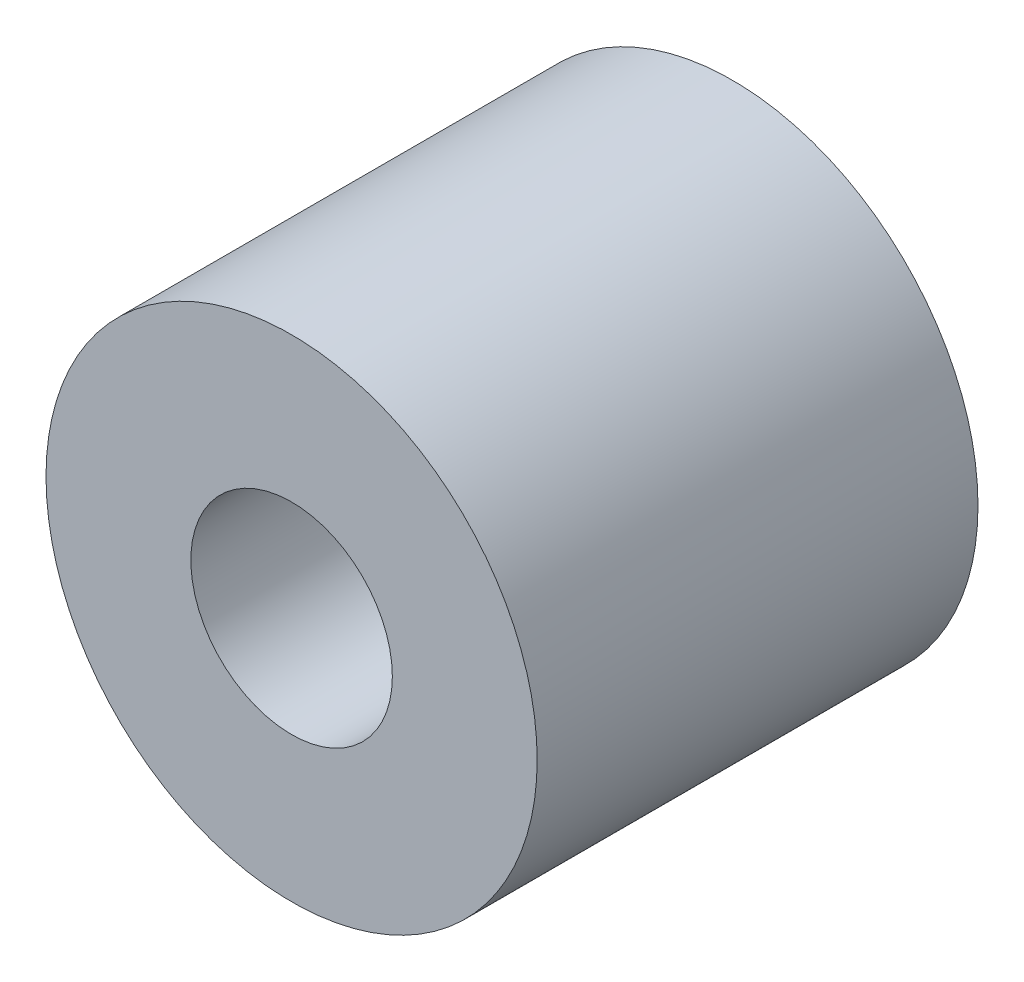
from build123d import *

# Parameters (mm, degrees)
SKETCH1_R           = 3.9
SKETCH1_R_2         = 1.6
BOSS_EXTRUDE1_DEPTH = 7


with BuildPart() as part:
    # Sketch1 → Boss-Extrude1 (new body)
    with BuildSketch(Plane.XY):
        Circle(SKETCH1_R)
        Circle(SKETCH1_R_2, mode=Mode.SUBTRACT)
    extrude(amount=BOSS_EXTRUDE1_DEPTH)


solid = part.part
